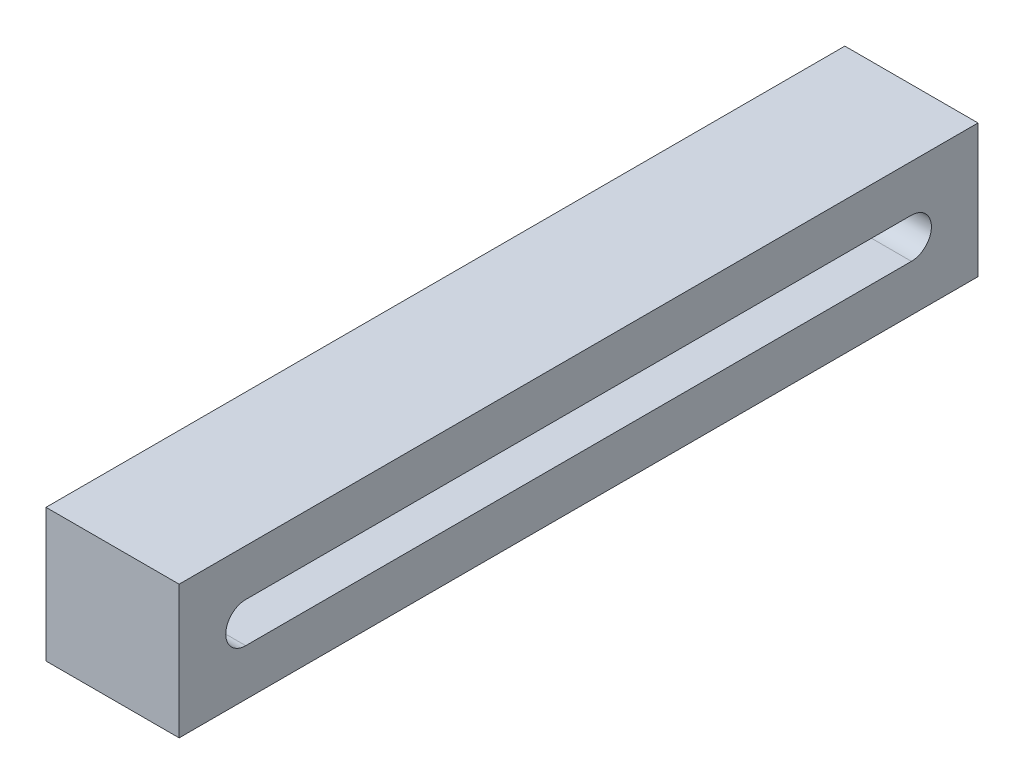
from build123d import *

# Parameters (mm, degrees)
SKETCH_1_W      = 60
SKETCH_1_H      = 10
EXTRUDE_1_DEPTH = 10


with BuildPart() as part:
    # 草图1 → 凸台-拉伸1 (new body)
    with BuildSketch(Plane(origin=(0, 0, 0), x_dir=(0, 0, -1), z_dir=(1, 0, 0))):
        with Locations((28.433962264, 4.621952123)):
            Rectangle(SKETCH_1_W, SKETCH_1_H)
        with BuildLine():
            Line((3.433962264, 6.121952123), (53.433962264, 6.121952123))
            ThreePointArc((53.433962264, 6.121952123), (54.933962264, 4.621952123), (53.433962264, 3.121952123))
            Line((53.433962264, 3.121952123), (3.433962264, 3.121952123))
            ThreePointArc((3.433962264, 3.121952123), (1.933962264, 4.621952123), (3.433962264, 6.121952123))
        make_face(mode=Mode.SUBTRACT)
    extrude(amount=EXTRUDE_1_DEPTH)


solid = part.part
